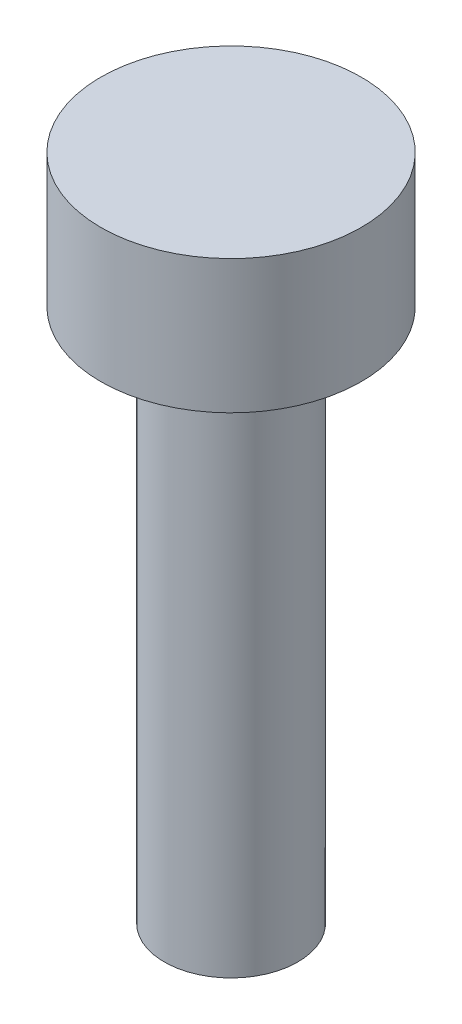
from build123d import *

# Parameters (mm, degrees)
SKETCH1_R           = 1.95
BOSS_EXTRUDE1_DEPTH = 2
SKETCH2_R           = 1
BOSS_EXTRUDE2_DEPTH = 8


with BuildPart() as part:
    # Sketch1 → Boss-Extrude1 (new body)
    with BuildSketch(Plane(origin=(0, 0, 0), x_dir=(1, 0, 0), z_dir=(0, 1, 0))):
        Circle(SKETCH1_R)
    extrude(amount=BOSS_EXTRUDE1_DEPTH)

    # Sketch2 → Boss-Extrude2 (add)
    with BuildSketch(Plane.XZ):
        Circle(SKETCH2_R)
    extrude(amount=BOSS_EXTRUDE2_DEPTH)


solid = part.part
